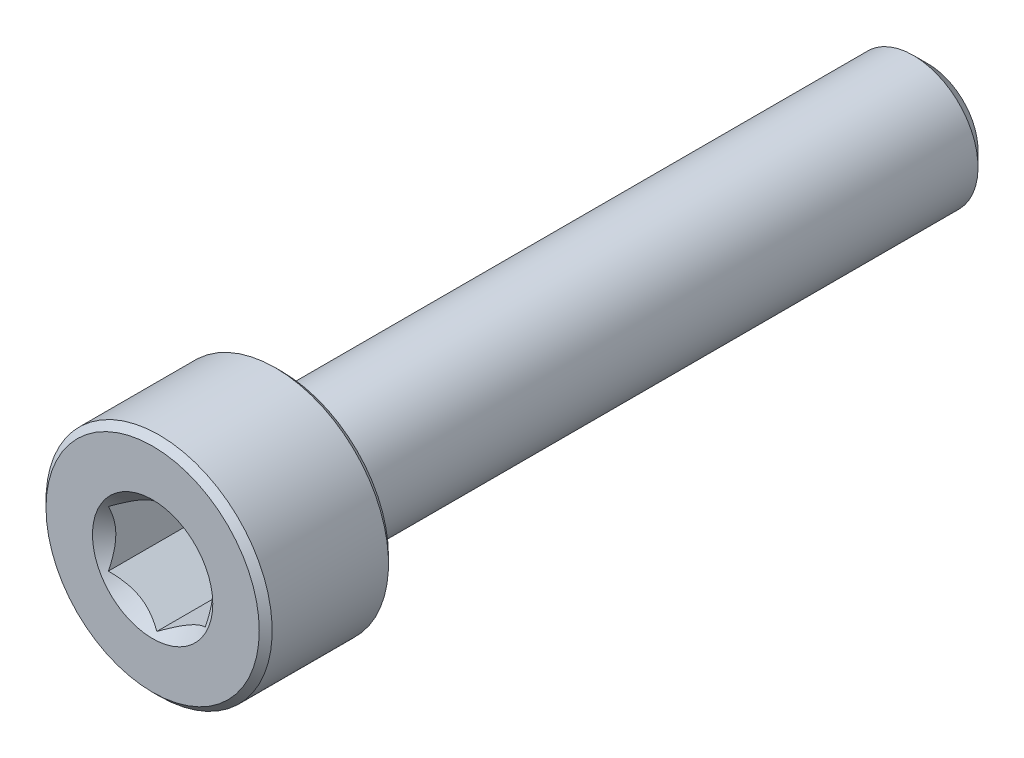
from build123d import *

# Parameters (mm, degrees)
CUT_EXTRUDE1_DEPTH = 3
SKETCH4_R          = 1.861954618
CUT_EXTRUDE2_DEPTH = 3
CUT_EXTRUDE2_DRAFT = -45


with BuildPart() as part:
    # Sketch2 → Revolve1 (revolve)
    with BuildSketch(Plane(origin=(0, 0, 0), x_dir=(0, 0, -1), z_dir=(1, 0, 0))):
        with BuildLine():
            Line((-12, 0), (-12, 3.3))
            Line((-12, 3.3), (-11.8, 3.5))
            Line((-11.8, 3.5), (-8.2, 3.5))
            Line((-8.2, 3.5), (-8, 3.3))
            Line((-8, 3.3), (-8, 2.2))
            ThreePointArc((-8, 2.2), (-7.941421356, 2.058578644), (-7.8, 2))
            Line((-7.8, 2), (11.545336663, 2))
            Line((11.545336663, 2), (12, 1.545336663))
            Line((12, 1.545336663), (12, 0))
            Line((12, 0), (-12, 0))
        make_face()
    revolve(axis=Axis((0, 0, -12), (0, 0, 1)))

    # Sketch3 → Cut-Extrude1 (cut)
    with BuildSketch(Plane.XY.offset(12)):
        Polygon((1.5, -0.866025404), (1.5, 0.866025404), (0, 1.732050808), (-1.5, 0.866025404), (-1.5, -0.866025404), (0, -1.732050808), align=None)
    extrude(amount=-CUT_EXTRUDE1_DEPTH, mode=Mode.SUBTRACT)


with BuildPart() as cut_extrude2_tool:
    # Sketch4 → Cut-Extrude2 (with draft: the straight prism first)
    with BuildSketch(Plane.XY.offset(12)):
        Circle(SKETCH4_R)
    extrude(amount=-CUT_EXTRUDE2_DEPTH)
    # Cut-Extrude2: the draft: its side faces are tilted about the plane it starts from
    cut_extrude2_sides = [cut_extrude2_tool.faces().sort_by_distance(p)[0] for p in [
        (-1.861954618, 0, 10.5),
    ]]
    draft(cut_extrude2_sides, Plane.XY.offset(12), CUT_EXTRUDE2_DRAFT)


with BuildPart() as part_1:
    add(part.part)

    # Cut-Extrude2: cut by cut_extrude2_tool
    add(cut_extrude2_tool.part, mode=Mode.SUBTRACT)


solid = part_1.part
